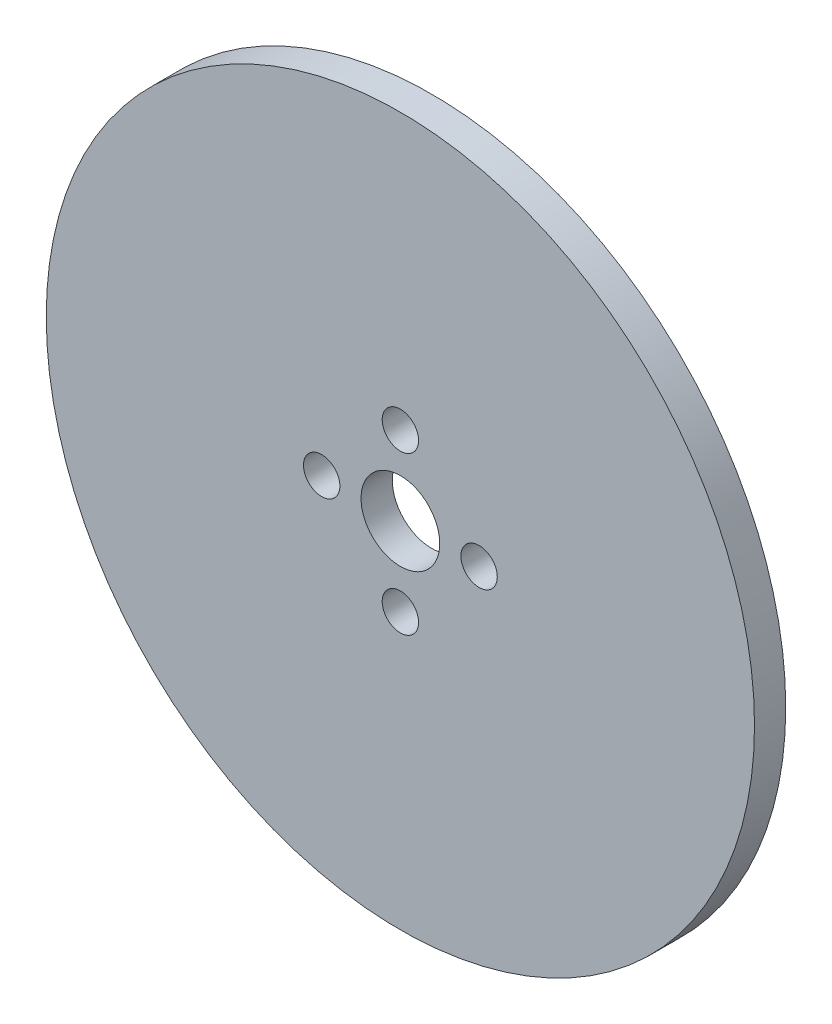
from build123d import *

# Parameters (mm, degrees)
SKETCH1_R           = 4
SKETCH1_R_2         = 1.85
BOSS_EXTRUDE1_DEPTH = 3.175


with BuildPart() as part:
    # Sketch1 → Boss-Extrude1 (new body)
    with BuildSketch(Plane.XY):
        with BuildLine():
            ThreePointArc((-36, 0), (0, -36), (36, 0))
            ThreePointArc((36, 0), (0, 36), (-36, 0))
        make_face()
        Circle(SKETCH1_R, mode=Mode.SUBTRACT)
        with Locations((-8, 0)):
            Circle(SKETCH1_R_2, mode=Mode.SUBTRACT)
        with Locations((0, -8)):
            Circle(SKETCH1_R_2, mode=Mode.SUBTRACT)
        with Locations((0, 8)):
            Circle(SKETCH1_R_2, mode=Mode.SUBTRACT)
        with Locations((8, 0)):
            Circle(SKETCH1_R_2, mode=Mode.SUBTRACT)
    extrude(amount=BOSS_EXTRUDE1_DEPTH)


solid = part.part
